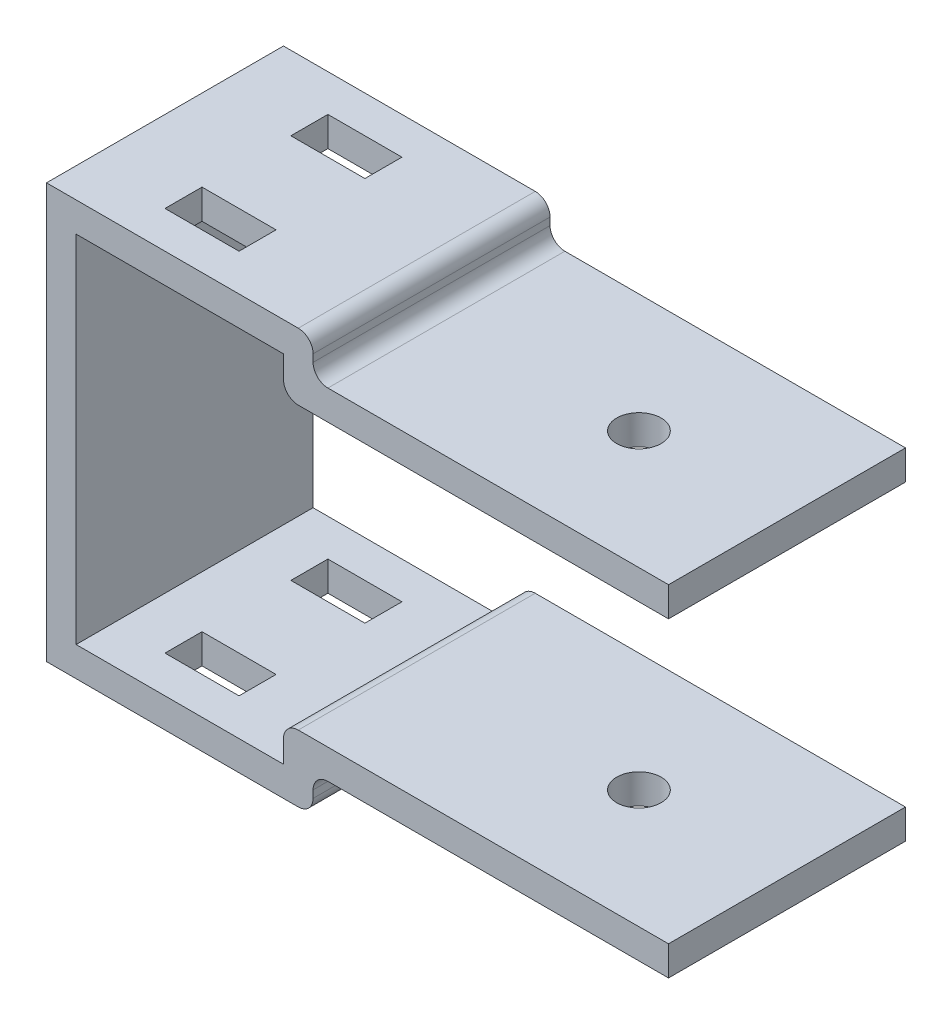
from build123d import *

# Parameters (mm, degrees)
Y_KSEKLIK_EKSTR_ZYON1_DEPTH = 8
IZIM2_R                     = 1.5
KES_EKSTR_ZYON1_DEPTH       = 18
IZIM3_W                     = 5
IZIM3_H                     = 2.5
KES_EKSTR_ZYON2_DEPTH       = 36


with BuildPart() as part:
    # Çizim1 → Yükseklik-Ekstrüzyon1 (new body, symmetric)
    with BuildSketch(Plane.XY):
        with BuildLine():
            ThreePointArc((-11.99936312, 14), (-11.292256338, 13.707106781), (-10.99936312, 13))
            Line((-10.99936312, 13), (-10.99936312, 12.499999979))
            ThreePointArc((-10.99936312, 12.499999979), (-10.706469901, 11.792893197), (-9.99936312, 11.499999979))
            Line((-9.99936312, 11.499999979), (13.00063688, 11.499999979))
            Line((13.00063688, 11.499999979), (13.00063688, 9.499999979))
            Line((13.00063688, 9.499999979), (-11.99936312, 9.499999979))
            ThreePointArc((-11.99936312, 9.499999979), (-12.706469901, 9.792893197), (-12.99936312, 10.499999979))
            Line((-12.99936312, 10.499999979), (-12.99936312, 12))
            Line((-12.99936312, 12), (-27.00063688, 12))
            Line((-27.00063688, 12), (-27.00063688, -12))
            Line((-27.00063688, -12), (-13.00063688, -12))
            Line((-13.00063688, -12), (-13.00063688, -10.499999979))
            ThreePointArc((-13.00063688, -10.499999979), (-12.707743662, -9.792893197), (-12.00063688, -9.499999979))
            Line((-12.00063688, -9.499999979), (12.99936312, -9.499999979))
            Line((12.99936312, -9.499999979), (12.99936312, -11.499999979))
            Line((12.99936312, -11.499999979), (-10.00063688, -11.499999979))
            ThreePointArc((-10.00063688, -11.499999979), (-10.707743662, -11.792893197), (-11.00063688, -12.499999979))
            Line((-11.00063688, -12.499999979), (-11.00063688, -13))
            ThreePointArc((-11.00063688, -13), (-11.293530099, -13.707106781), (-12.00063688, -14))
            Line((-12.00063688, -14), (-12.86760717, -14))
            Line((-12.86760717, -14), (-29.00063688, -14))
            Line((-29.00063688, -14), (-29.00063688, 14))
            Line((-29.00063688, 14), (-12.99936312, 14))
            Line((-12.99936312, 14), (-11.99936312, 14))
        make_face()
    extrude(amount=Y_KSEKLIK_EKSTR_ZYON1_DEPTH, both=True)

    # Çizim2 → Kes-Ekstrüzyon1 (cut, symmetric)
    with BuildSketch(Plane(origin=(0, 0, 0), x_dir=(1, 0, 0), z_dir=(0, 1, 0))):
        with Locations((3.00063688, 0)):
            Circle(IZIM2_R)
    extrude(amount=KES_EKSTR_ZYON1_DEPTH, both=True, mode=Mode.SUBTRACT)

    # Çizim3 → Kes-Ekstrüzyon2 (cut)
    with BuildSketch(Plane(origin=(0, 14, 0), x_dir=(1, 0, 0), z_dir=(0, 1, 0))):
        with Locations((-21.00063688, -4.25)):
            Rectangle(IZIM3_W, IZIM3_H)
        with Locations((-21.00063688, 4.25)):
            Rectangle(IZIM3_W, IZIM3_H)
    extrude(amount=-KES_EKSTR_ZYON2_DEPTH, mode=Mode.SUBTRACT)


solid = part.part
